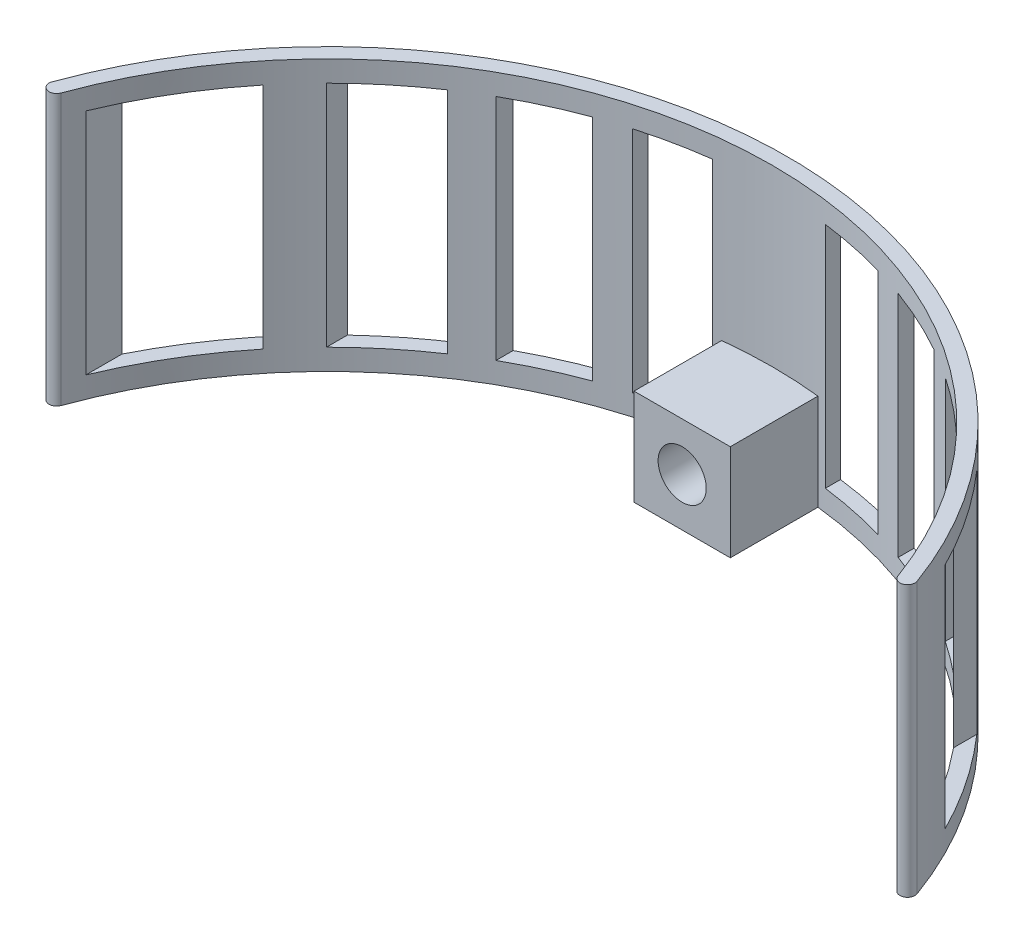
from build123d import *

# Parameters (mm, degrees)
BOSS_EXTRUDE1_DEPTH = 90
BOSS_EXTRUDE2_REACH = 155
SKETCH2_W           = 32
SKETCH2_H           = 32
SKETCH2_R           = 8
SKETCH3_R           = 8
CUT_EXTRUDE1_DEPTH  = 210
SKETCH4_W           = 32
SKETCH4_H           = 118
CUT_EXTRUDE2_DEPTH  = 210
SKETCH5_W           = 22
SKETCH5_H           = 76
CUT_EXTRUDE4_DEPTH  = 210


with BuildPart() as part:
    # Sketch1 → Boss-Extrude1 (new body)
    with BuildSketch(Plane(origin=(0, 0, 0), x_dir=(1, 0, 0), z_dir=(0, 1, 0))):
        with BuildLine():
            ThreePointArc((139.074507876, 50.618981212), (0, 148), (-139.074507876, 50.618981212))
            ThreePointArc((-139.074507876, 50.618981212), (-142.278789787, 49.124800019), (-143.77297098, 52.329081929))
            ThreePointArc((-143.77297098, 52.329081929), (0, 153), (143.77297098, 52.329081929))
            ThreePointArc((143.77297098, 52.329081929), (142.278789787, 49.124800019), (139.074507876, 50.618981212))
        make_face()
    extrude(amount=BOSS_EXTRUDE1_DEPTH)

    # Sketch2 → Boss-Extrude2 (add, up to next)
    with BuildSketch(Plane.XY, mode=Mode.PRIVATE) as boss_extrude2_sk1:
        with Locations((0, 16)):
            Rectangle(SKETCH2_W, SKETCH2_H)
        with Locations((0, 16)):
            Circle(SKETCH2_R, mode=Mode.SUBTRACT)
    boss_extrude2_tool1 = extrude(boss_extrude2_sk1.sketch, amount=-BOSS_EXTRUDE2_REACH, mode=Mode.PRIVATE) - part.part
    add(boss_extrude2_tool1.solids().sort_by_distance((0, 0.452548, 0))[0])

    # Sketch3 → Cut-Extrude1 (cut)
    with BuildSketch(Plane.XY):
        with Locations((0, 16)):
            Circle(SKETCH3_R)
    extrude(amount=-CUT_EXTRUDE1_DEPTH, mode=Mode.SUBTRACT)

    # Sketch4 → Cut-Extrude2 (cut)
    with BuildSketch(Plane(origin=(0, 32, 0), x_dir=(1, 0, 0), z_dir=(0, 1, 0))):
        with Locations((0, 59)):
            Rectangle(SKETCH4_W, SKETCH4_H)
    extrude(amount=-CUT_EXTRUDE2_DEPTH, mode=Mode.SUBTRACT)

    # Sketch5 → Cut-Extrude4 (cut)
    with BuildSketch(Plane(origin=(0, 0, -153), x_dir=(-1, 0, 0), z_dir=(0, 0, -1))):
        with Locations((-125.77297098, 45)):
            Rectangle(SKETCH5_W, SKETCH5_H)
        with Locations((-93.77297098, 45)):
            Rectangle(SKETCH5_W, SKETCH5_H)
        with Locations((-61.77297098, 45)):
            Rectangle(SKETCH5_W, SKETCH5_H)
        with Locations((29.77297098, 45)):
            Rectangle(SKETCH5_W, SKETCH5_H)
        with Locations((61.77297098, 45)):
            Rectangle(SKETCH5_W, SKETCH5_H)
        with Locations((93.77297098, 45)):
            Rectangle(SKETCH5_W, SKETCH5_H)
        with Locations((125.77297098, 45)):
            Rectangle(SKETCH5_W, SKETCH5_H)
        with Locations((-29.77297098, 45)):
            Rectangle(SKETCH5_W, SKETCH5_H)
    extrude(amount=-CUT_EXTRUDE4_DEPTH, mode=Mode.SUBTRACT)


solid = part.part
